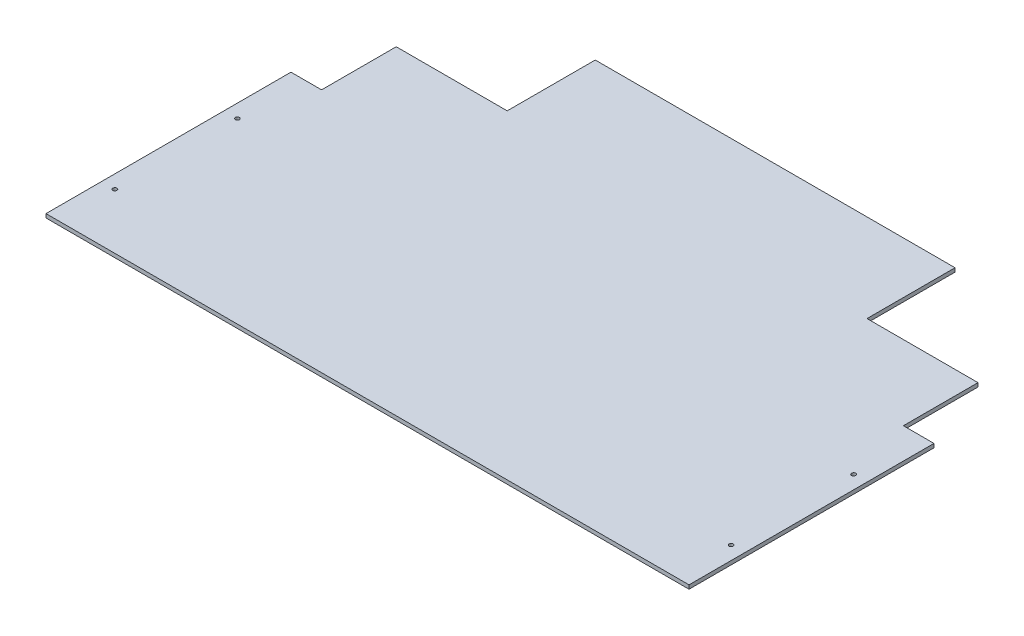
from build123d import *

# Parameters (mm, degrees)
SKETCH1_R           = 3.3734375
BOSS_EXTRUDE1_DEPTH = 6.35


with BuildPart() as part:
    # Sketch1 → Boss-Extrude1 (new body)
    with BuildSketch(Plane(origin=(0, 0, 0), x_dir=(1, 0, 0), z_dir=(0, 1, 0))):
        Polygon((1016, 406.4), (1066.8, 406.4), (1066.8, 0), (0, 0), (0, 406.4), (50.8, 406.4), (50.8, 530.225), (234.95, 530.225), (234.95, 676.275), (831.85, 676.275), (831.85, 530.225), (1016, 530.225), align=None)
        with Locations((22.225, 92.075)):
            Circle(SKETCH1_R, mode=Mode.SUBTRACT)
        with Locations((1044.575, 92.075)):
            Circle(SKETCH1_R, mode=Mode.SUBTRACT)
        with Locations((22.225, 295.275)):
            Circle(SKETCH1_R, mode=Mode.SUBTRACT)
        with Locations((1044.575, 295.275)):
            Circle(SKETCH1_R, mode=Mode.SUBTRACT)
    extrude(amount=BOSS_EXTRUDE1_DEPTH)


solid = part.part
